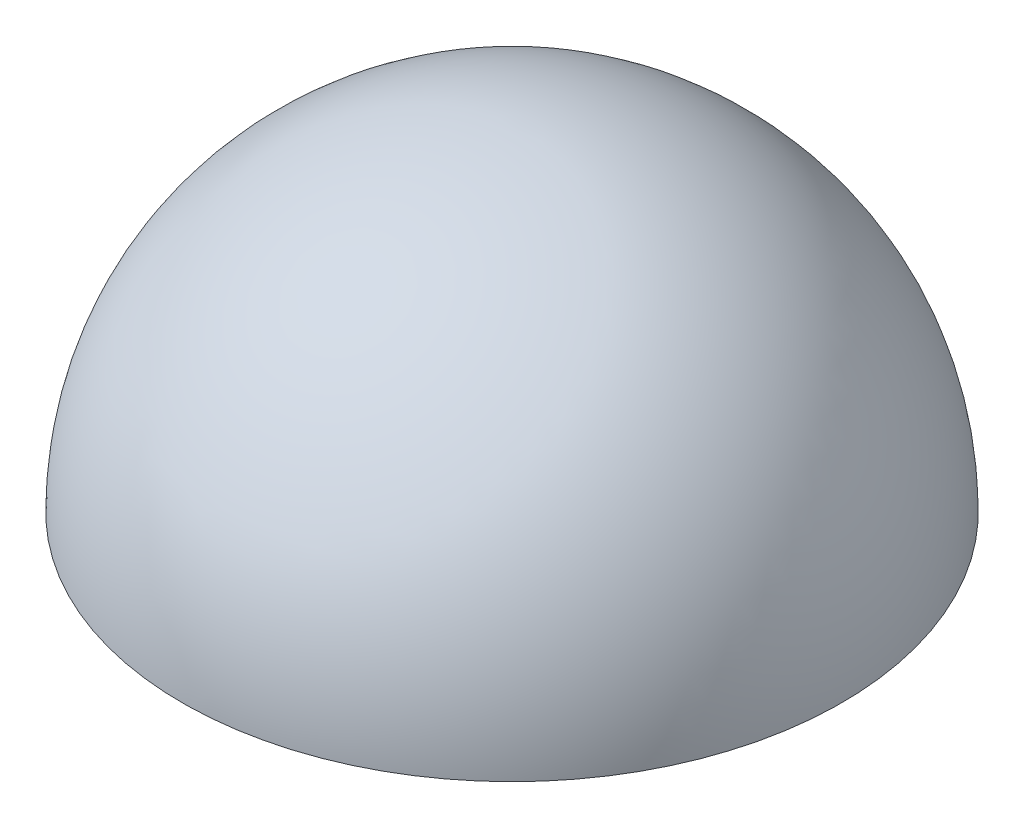
from build123d import *

# Parameters (mm, degrees)
REVOLVE1_ANGLE      = 180
SKETCH4_R           = 50
BOSS_EXTRUDE1_DEPTH = 7
SKETCH5_R           = 4
SKETCH5_R_2         = 1.5
BOSS_EXTRUDE2_DEPTH = 10
SKETCH6_R           = 27.5
CUT_EXTRUDE1_DEPTH  = 10
BOSS_EXTRUDE3_DEPTH = 7
SKETCH8_R           = 3
BOSS_EXTRUDE4_DEPTH = 15
BOSS_EXTRUDE5_DEPTH = 10


with BuildPart() as part:
    # Sketch1 → Revolve1 (revolve)
    with BuildSketch(Plane(origin=(0, 0, 0), x_dir=(1, 0, 0), z_dir=(0, 1, 0))):
        with BuildLine():
            Line((1.491717845, 54.979766986), (-1.491717845, -54.979766986))
            ThreePointArc((-1.491717845, -54.979766986), (54.979766986, -1.491717845), (1.491717845, 54.979766986))
        make_face()
    revolve(axis=Axis((1.491717845, 0, -54.979766986), (-0.027122143, 0, 0.999632127)), revolution_arc=REVOLVE1_ANGLE)

    # Sketch2 → Cut-Revolve1 (revolve, cut)
    with BuildSketch(Plane.XZ):
        with BuildLine():
            Line((49.980692072, 1.389395568), (-49.980692072, -1.389395568))
            ThreePointArc((-49.980692072, -1.389395568), (-1.389395568, 49.980692072), (49.980692072, 1.389395568))
        make_face()
    revolve(axis=Axis((49.980692072, 0, 1.389395568), (-0.999613841, 0, -0.027787911)), mode=Mode.SUBTRACT)

    # Sketch4 → Boss-Extrude1 (add)
    with BuildSketch(Plane.XZ):
        Circle(SKETCH4_R)
    extrude(amount=-BOSS_EXTRUDE1_DEPTH)

    # Sketch5 → Boss-Extrude2 (add)
    with BuildSketch(Plane.XZ):
        with Locations((0, 35)):
            Circle(SKETCH5_R)
        with Locations((0, 35)):
            Circle(SKETCH5_R_2, mode=Mode.SUBTRACT)
        with Locations((30.310889132, -17.5)):
            Circle(SKETCH5_R)
        with Locations((30.310889132, -17.5)):
            Circle(SKETCH5_R_2, mode=Mode.SUBTRACT)
        with Locations((-30.310889132, -17.5)):
            Circle(SKETCH5_R)
        with Locations((-30.310889132, -17.5)):
            Circle(SKETCH5_R_2, mode=Mode.SUBTRACT)
    extrude(amount=BOSS_EXTRUDE2_DEPTH)

    # Sketch6 → Cut-Extrude1 (cut)
    with BuildSketch(Plane.XZ):
        Circle(SKETCH6_R)
    extrude(amount=-CUT_EXTRUDE1_DEPTH, mode=Mode.SUBTRACT)

    # Sketch7 → Boss-Extrude3 (add)
    with BuildSketch(Plane.XZ):
        with BuildLine():
            Line((-29.59626463, 3), (-6.873863542, 3))
            ThreePointArc((-6.873863542, 3), (-5.303300859, 5.303300859), (-3, 6.873863542))
            Line((-3, 6.873863542), (-3, 29.076054117))
            Line((-3, 29.076054117), (3, 29.076054117))
            Line((3, 29.076054117), (3, 6.873863542))
            ThreePointArc((3, 6.873863542), (5.303300859, 5.303300859), (6.873863542, 3))
            Line((6.873863542, 3), (29.260564873, 3))
            Line((29.260564873, 3), (29.260564873, -3))
            Line((29.260564873, -3), (6.873863542, -3))
            ThreePointArc((6.873863542, -3), (5.303300859, -5.303300859), (3, -6.873863542))
            Line((3, -6.873863542), (3, -30.682999102))
            Line((3, -30.682999102), (-3, -30.682999102))
            Line((-3, -30.682999102), (-3, -6.873863542))
            ThreePointArc((-3, -6.873863542), (-5.303300859, -5.303300859), (-6.873863542, -3))
            Line((-6.873863542, -3), (-29.59626463, -3))
            Line((-29.59626463, -3), (-29.59626463, 3))
        make_face()
    extrude(amount=-BOSS_EXTRUDE3_DEPTH)

    # Sketch8 → Boss-Extrude4 (add)
    with BuildSketch(Plane.XZ):
        Circle(SKETCH8_R)
    extrude(amount=BOSS_EXTRUDE4_DEPTH)

    # Sketch9 → Boss-Extrude5 (add)
    with BuildSketch(Plane.XZ):
        Polygon((1, 1), (4.3, 1), (4.3, -1), (1, -1), (1, -4.3), (-1, -4.3), (-1, -1), (-4.3, -1), (-4.3, 1), (-1, 1), (-1, 4.3), (1, 4.3), align=None)
    extrude(amount=BOSS_EXTRUDE5_DEPTH)


solid = part.part
